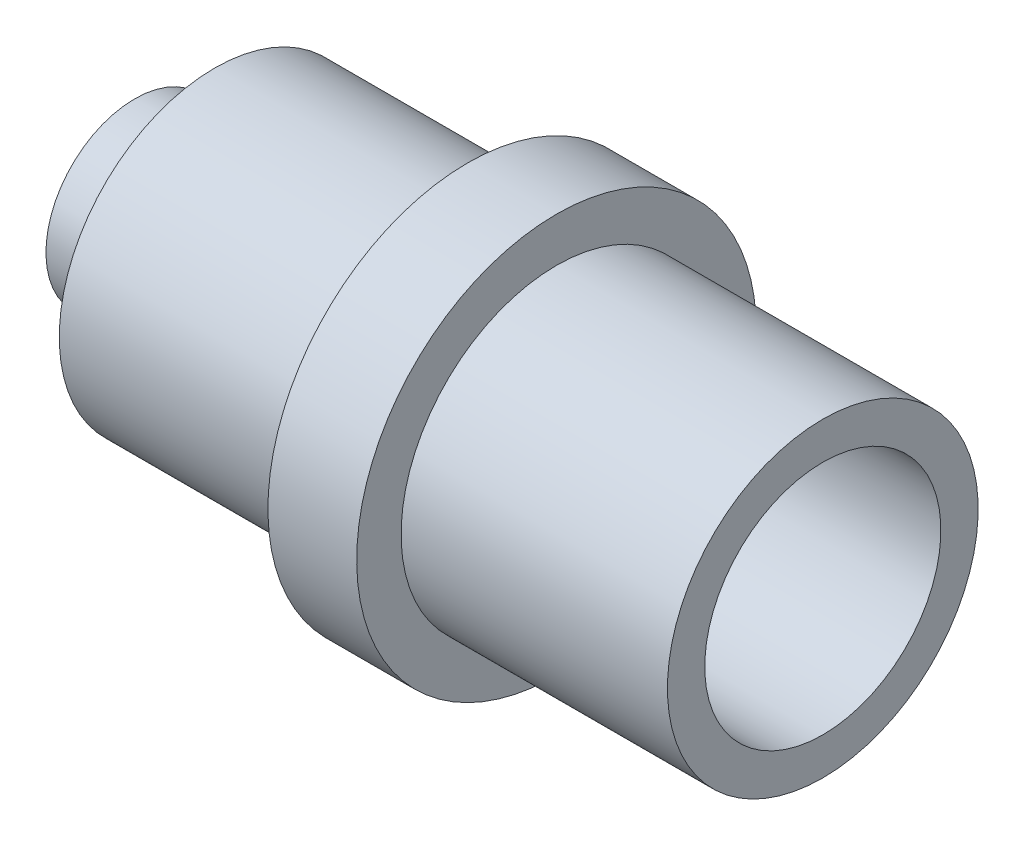
from build123d import *

# Parameters (mm, degrees)
SKETCH2_R          = 2.659658838
CUT_EXTRUDE1_DEPTH = 5


with BuildPart() as part:
    # Sketch1 → Revolve1 (revolve)
    with BuildSketch(Plane.XY):
        Polygon((0, 0), (0, -3.5), (-6, -3.5), (-6, -4.5), (-8, -4.5), (-8, -3.5), (-13.7, -3.5), (-13.7, -2), (-15.5, -2), (-15.5, 0), align=None)
    revolve(axis=Axis((0, 0, 0), (-1, 0, 0)))

    # Sketch2 → Cut-Extrude1 (cut)
    with BuildSketch(Plane(origin=(0, 0, 0), x_dir=(0, 0, -1), z_dir=(1, 0, 0))):
        Circle(SKETCH2_R)
    extrude(amount=-CUT_EXTRUDE1_DEPTH, mode=Mode.SUBTRACT)


solid = part.part
